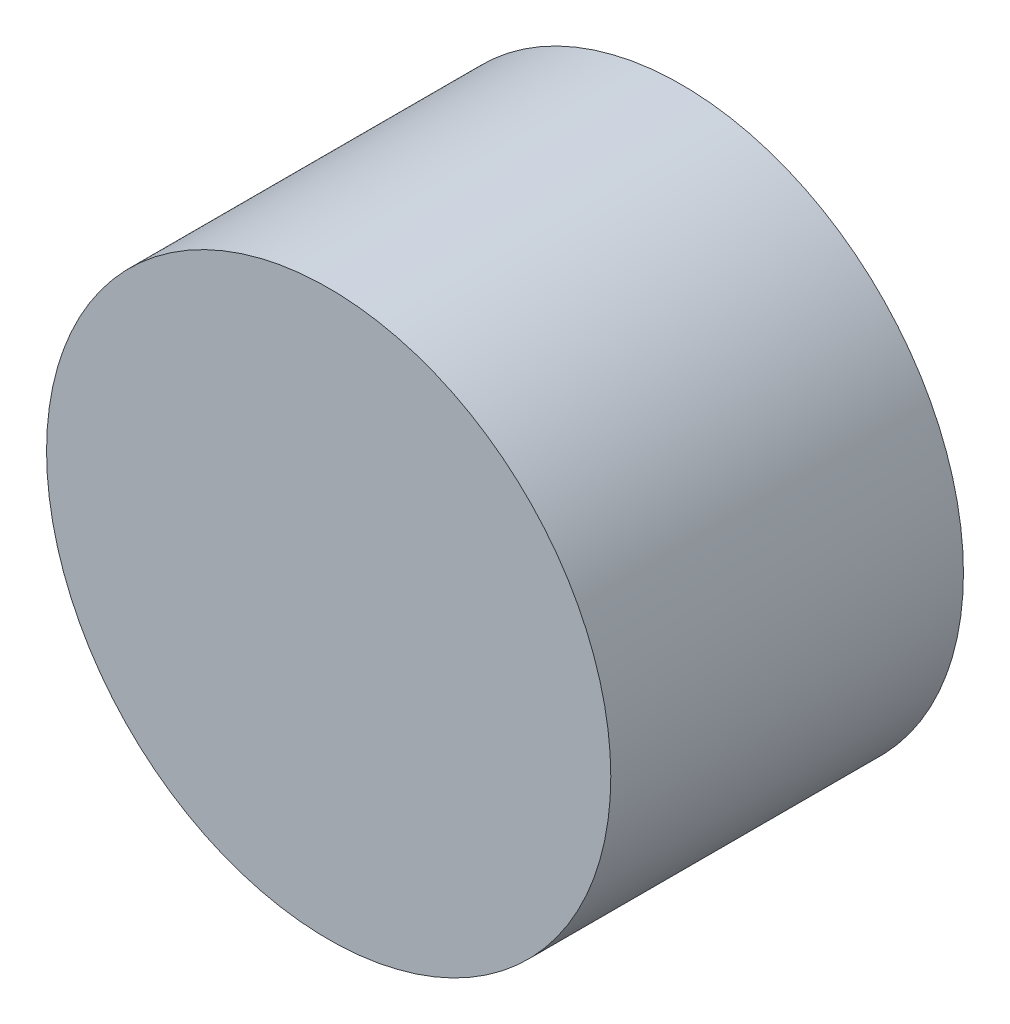
from build123d import *

# Parameters (mm, degrees)
BOSS_EXTRUDE1_DEPTH = 25


with BuildPart() as part:
    # Sketch2 → Boss-Extrude1 (new body)
    with BuildSketch(Plane.XY):
        with BuildLine():
            ThreePointArc((-250, 67.5), (-230, 87.5), (-250, 107.5))
            ThreePointArc((-250, 107.5), (-270, 87.5), (-250, 67.5))
        make_face()
    extrude(amount=BOSS_EXTRUDE1_DEPTH)


solid = part.part
